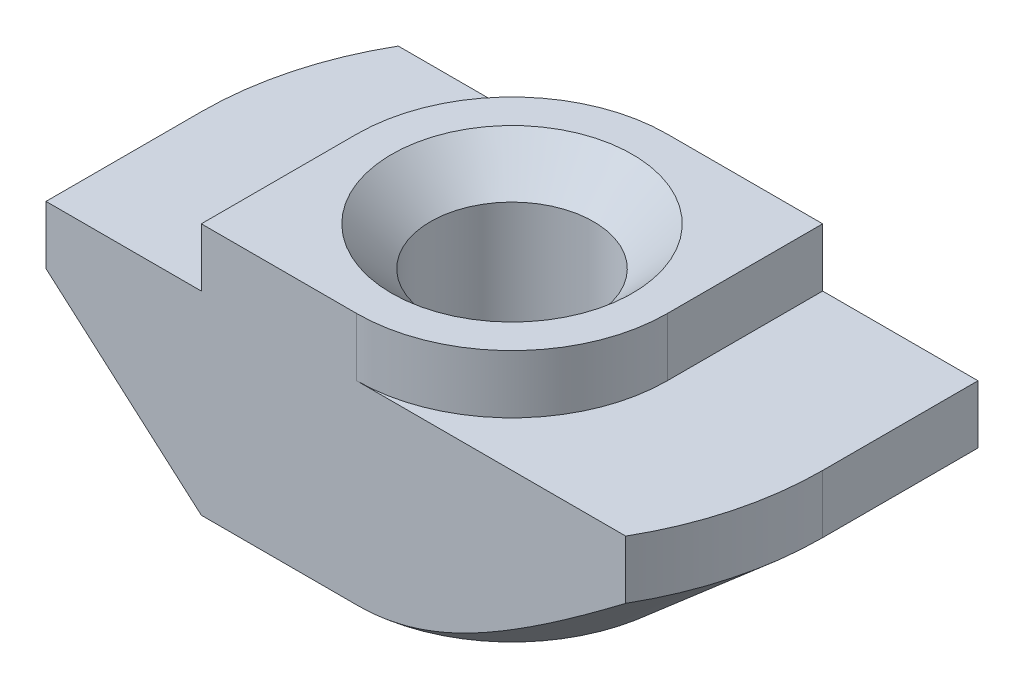
from build123d import *

# Parameters (mm, degrees)
EXTRUDE_1_DEPTH     = 4
CUT_EXTRUDE_1_DEPTH = 1.5
CUT_EXTRUDE_2_DEPTH = 6


with BuildPart() as part:
    # Эскиз1 → Бобышка-Вытянуть1 (new body, symmetric)
    with BuildSketch(Plane.XY):
        Polygon((4, 0), (-4, 0), (-4, -1.5), (-8, -1.5), (-8, -6.5), (8, -6.5), (8, -1.5), (4, -1.5), align=None)
    extrude(amount=EXTRUDE_1_DEPTH, both=True)

    # Эскиз3 → Отверстие обработанное метчиком M52 (revolve, cut)
    with BuildSketch(Plane(origin=(0, 0, 0), x_dir=(0, 0, 1), z_dir=(1, 0, 0))):
        Polygon((0, 0), (0, 6.5), (3.1, 6.5), (2.1, 5.5), (2.1, 1), (3.1, 0), align=None)
    revolve(axis=Axis((0, 6.35, 0), (0, -1, 0)), mode=Mode.SUBTRACT)

    # Эскиз4 → Вырез-Вытянуть1 (cut)
    with BuildSketch(Plane(origin=(0, 0, 0), x_dir=(1, 0, 0), z_dir=(0, 1, 0))):
        with BuildLine():
            Line((-4, 4), (-4, 0))
            ThreePointArc((-4, 0), (-2.828427125, 2.828427125), (0, 4))
            Line((0, 4), (-4, 4))
        make_face()
        with BuildLine():
            Line((0, -4), (4, -4))
            Line((4, -4), (4, 0))
            ThreePointArc((4, 0), (2.828427125, -2.828427125), (0, -4))
        make_face()
    extrude(amount=-CUT_EXTRUDE_1_DEPTH, mode=Mode.SUBTRACT)

    # Эскиз5 → Вырез-Вытянуть2 (cut, through all)
    with BuildSketch(Plane(origin=(0, -1.5, 0), x_dir=(1, 0, 0), z_dir=(0, 1, 0))):
        with BuildLine():
            Line((-8, 0), (-8, 4))
            Line((-8, 4), (-6.92820323, 4))
            ThreePointArc((-6.92820323, 4), (-7.72740661, 2.070552361), (-8, 0))
        make_face()
        with BuildLine():
            Line((8, 0), (8, -4))
            Line((8, -4), (6.92820323, -4))
            ThreePointArc((6.92820323, -4), (7.72740661, -2.070552361), (8, 0))
        make_face()
    extrude(amount=-CUT_EXTRUDE_2_DEPTH, mode=Mode.SUBTRACT)

    # Вырез-По траектории1: sweep along a path in Эскиз7
    with BuildLine(Plane.XZ.offset(6.5)) as sweep_1_path:
        Line((0, 8), (-8, 8))
        Line((-8, 8), (-8, 0))
        ThreePointArc((-8, 0), (-5.656854249, -5.656854249), (0, -8))
        Line((0, -8), (8, -8))
        Line((8, -8), (8, 0))
        ThreePointArc((8, 0), (5.656854249, 5.656854249), (0, 8))
    # Эскиз6 → Вырез-По траектории1 (sweep, cut)
    with BuildSketch(Plane.XY.offset(4)):
        Polygon((-8, -3), (-8, -6.5), (-4, -6.5), align=None)
    sweep(path=sweep_1_path.line, transition=Transition.RIGHT, mode=Mode.SUBTRACT)


solid = part.part
